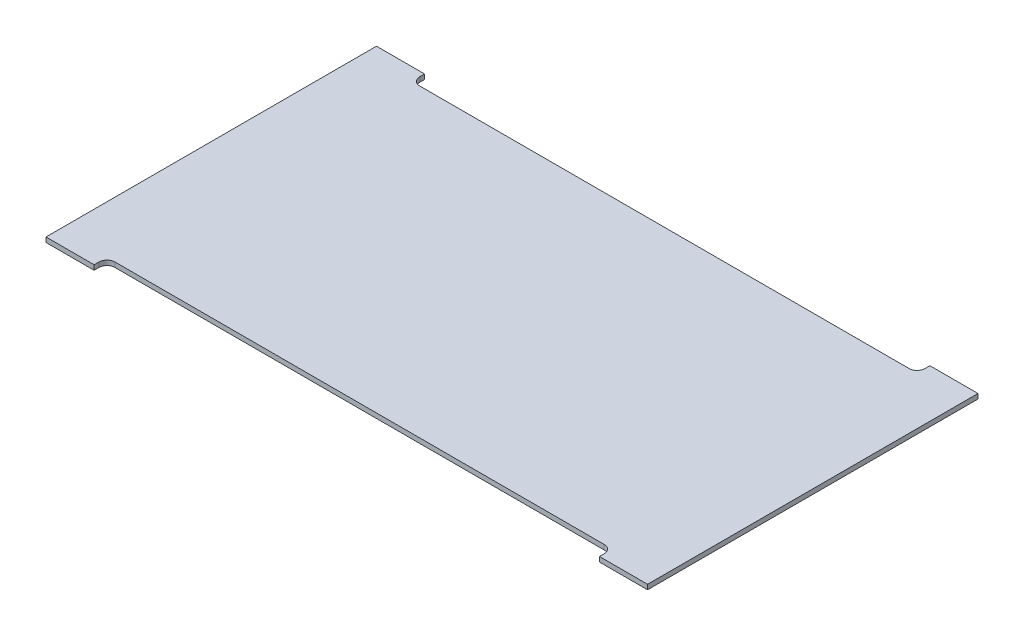
from build123d import *

# Parameters (mm, degrees)
BOSS_EXTRUDE1_DEPTH = 6
FILLET1_R           = 10


with BuildPart() as part:
    # Sketch1 → Boss-Extrude1 (new body)
    with BuildSketch(Plane(origin=(0, 0, 0), x_dir=(1, 0, 0), z_dir=(0, 1, 0))):
        Polygon((-750, 396), (-690, 396), (-690, 380), (-60, 380), (-60, 396), (0, 396), (0, -16), (-60, -16), (-60, 0), (-690, 0), (-690, -16), (-750, -16), align=None)
    extrude(amount=BOSS_EXTRUDE1_DEPTH)

    # Fillet1
    fillet1_edges = [part.edges().sort_by_distance(p)[0] for p in [
        (-690, 3, -380),
        (-60, 3, -380),
        (-60, 3, 0),
        (-690, 3, 0),
    ]]
    fillet(fillet1_edges, radius=FILLET1_R)


solid = part.part
